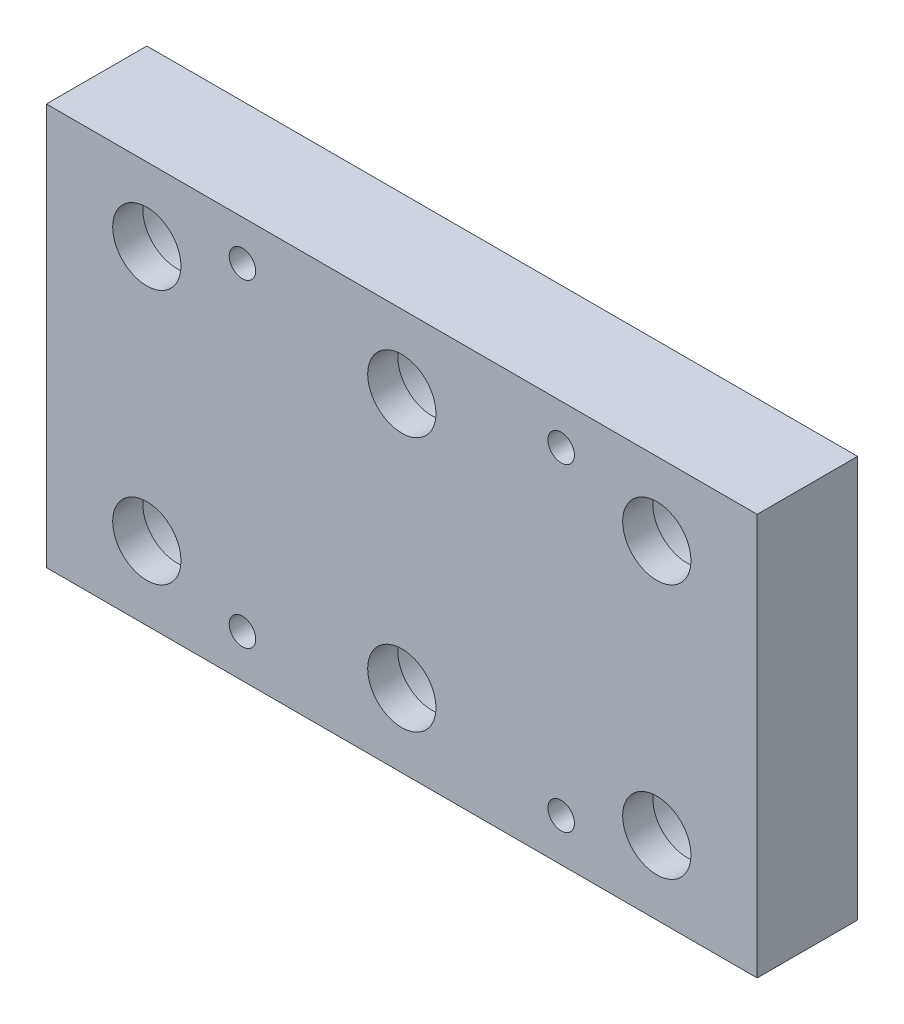
from build123d import *

# Parameters (mm, degrees)
SKETCH1_W           = 70.8
SKETCH1_H           = 40
BOSS_EXTRUDE1_DEPTH = 10
SKETCH2_R           = 1.32
CUT_EXTRUDE1_DEPTH  = 11
SKETCH3_R           = 3.4
CUT_EXTRUDE2_DEPTH  = 11
SKETCH4_R           = 5.375
CUT_EXTRUDE3_DEPTH  = 7


with BuildPart() as part:
    # Sketch1 → Boss-Extrude1 (new body)
    with BuildSketch(Plane.XY):
        Rectangle(SKETCH1_W, SKETCH1_H)
    extrude(amount=BOSS_EXTRUDE1_DEPTH)

    # Sketch2 → Cut-Extrude1 (cut, through all)
    with BuildSketch(Plane.XY.offset(10)):
        with Locations((15.875, -15.75)):
            Circle(SKETCH2_R)
        with Locations((-15.875, -15.75)):
            Circle(SKETCH2_R)
        with Locations((-15.875, 16)):
            Circle(SKETCH2_R)
        with Locations((15.875, 16)):
            Circle(SKETCH2_R)
    extrude(amount=-CUT_EXTRUDE1_DEPTH, mode=Mode.SUBTRACT)

    # Sketch3 → Cut-Extrude2 (cut, through all)
    with BuildSketch(Plane(origin=(0, 0, 0), x_dir=(-1, 0, 0), z_dir=(0, 0, -1))):
        with Locations((-25.4, -12.7)):
            Circle(SKETCH3_R)
        with Locations((0, -12.7)):
            Circle(SKETCH3_R)
        with Locations((25.4, -12.7)):
            Circle(SKETCH3_R)
        with Locations((0, 12.7)):
            Circle(SKETCH3_R)
        with Locations((25.4, 12.7)):
            Circle(SKETCH3_R)
        with Locations((-25.4, 12.7)):
            Circle(SKETCH3_R)
    extrude(amount=-CUT_EXTRUDE2_DEPTH, mode=Mode.SUBTRACT)

    # Sketch4 → Cut-Extrude3 (cut)
    with BuildSketch(Plane(origin=(0, 0, 0), x_dir=(-1, 0, 0), z_dir=(0, 0, -1))):
        with Locations((25.4, -12.7)):
            Circle(SKETCH4_R)
        with Locations((0, -12.7)):
            Circle(SKETCH4_R)
        with Locations((-25.4, -12.7)):
            Circle(SKETCH4_R)
        with Locations((0, 12.7)):
            Circle(SKETCH4_R)
        with Locations((-25.4, 12.7)):
            Circle(SKETCH4_R)
        with Locations((25.4, 12.7)):
            Circle(SKETCH4_R)
    extrude(amount=-CUT_EXTRUDE3_DEPTH, mode=Mode.SUBTRACT)


solid = part.part
